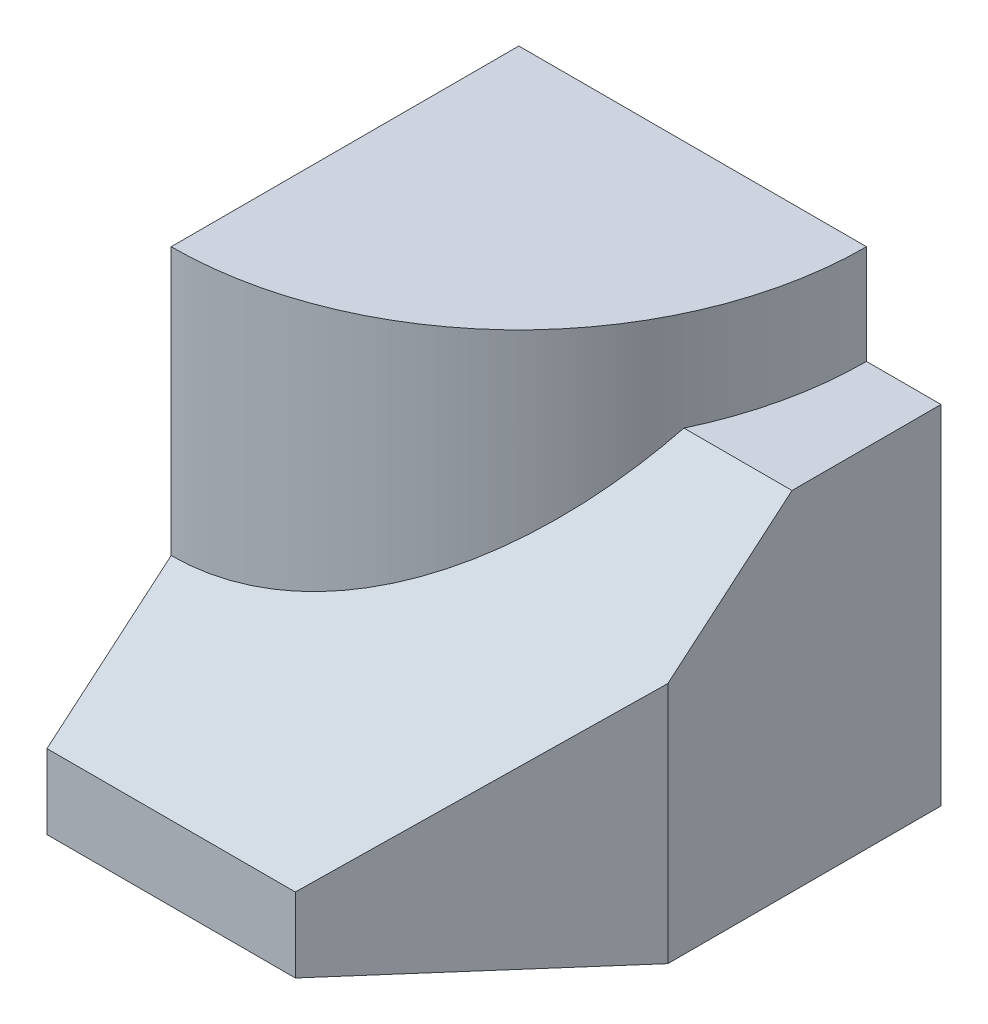
from build123d import *

# Parameters (mm, degrees)
EXTRUDE1_DEPTH = 90
EXTRUDE2_DEPTH = 85
EXTRUDE3_DEPTH = 91


with BuildPart() as part:
    # Sketch1 → Extrude1 (new body)
    with BuildSketch(Plane(origin=(0, 0, 0), x_dir=(1, 0, 0), z_dir=(0, 1, 0))):
        with BuildLine():
            Line((70, 0), (0, 0))
            Line((0, 0), (0, -70))
            ThreePointArc((0, -70), (49.497474683, -49.497474683), (70, 0))
        make_face()
    extrude(amount=EXTRUDE1_DEPTH)

    # Sketch2 → Extrude2 (add)
    with BuildSketch(Plane.ZY):
        Polygon((0, 70), (30, 70), (95, 15), (95, 0), (0, 0), align=None)
    extrude(amount=-EXTRUDE2_DEPTH)

    # Sketch3 → Extrude3 (cut, through all)
    with BuildSketch(Plane(origin=(0, 0, 0), x_dir=(1, 0, 0), z_dir=(0, 1, 0))):
        Polygon((85, -55), (50, -95), (85, -95), align=None)
    extrude(amount=EXTRUDE3_DEPTH, mode=Mode.SUBTRACT)


solid = part.part
